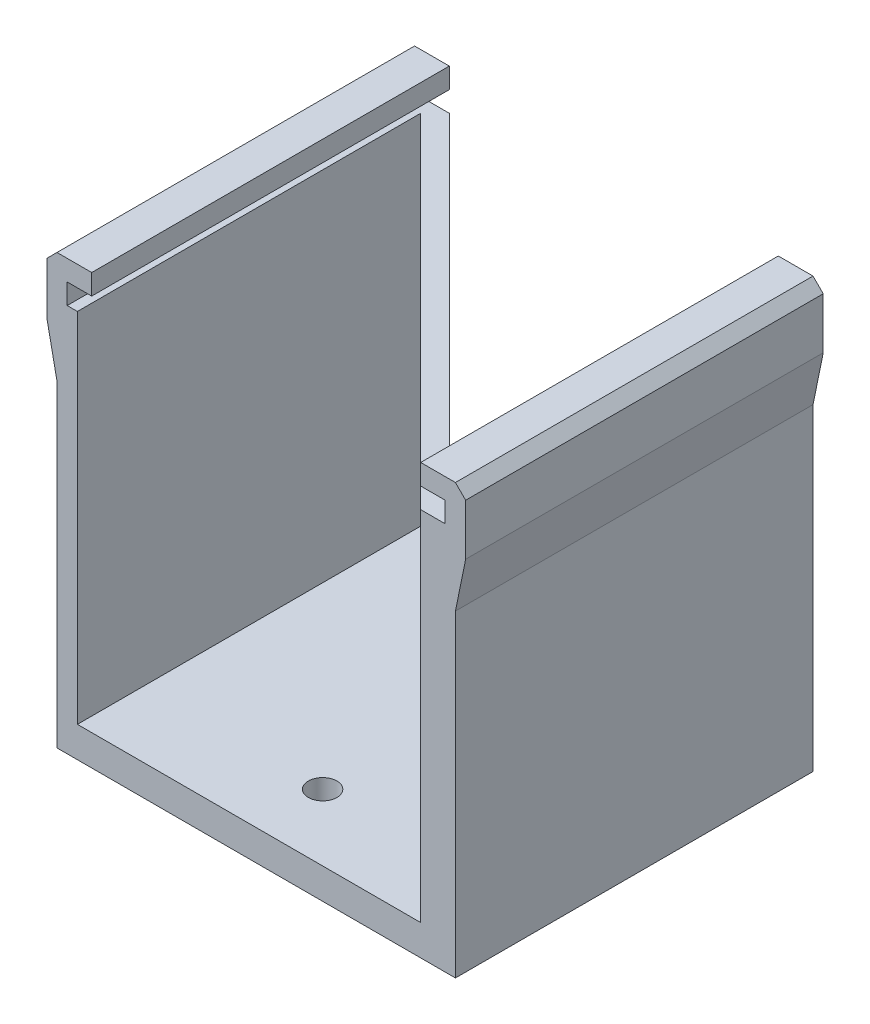
from build123d import *

# Parameters (mm, degrees)
SKETCH1_W            = 35
SKETCH1_H            = 35
BOSS_EXTRUDE1_DEPTH  = 3
BOSS_EXTRUDE2_DEPTH  = 35
SKETCH6_W            = 35
SKETCH6_H            = 38
BOSS_EXTRUDE8_DEPTH  = 2
SKETCH7_W            = 35
SKETCH7_H            = 38
BOSS_EXTRUDE9_DEPTH  = 2
SKETCH8_R            = 1.4
CUT_EXTRUDE1_DEPTH   = 10
SKETCH9_W            = 1
SKETCH9_H            = 35
BOSS_EXTRUDE10_DEPTH = 2
SKETCH10_W           = 3.4
SKETCH10_H           = 2
BOSS_EXTRUDE11_DEPTH = 35
BOSS_EXTRUDE12_DEPTH = 35


with BuildPart() as part:
    # Sketch1 → Boss-Extrude1 (new body)
    with BuildSketch(Plane(origin=(0, 0, 0), x_dir=(1, 0, 0), z_dir=(0, 1, 0))):
        with Locations((-17.5, 17.5)):
            Rectangle(SKETCH1_W, SKETCH1_H)
    extrude(amount=BOSS_EXTRUDE1_DEPTH)

    # Sketch2 → Boss-Extrude2 (add)
    with BuildSketch(Plane(origin=(0, 3, 0), x_dir=(1, 0, 0), z_dir=(0, 1, 0))):
        Polygon((-35, 33.6), (-1.4, 0), (0, 0), (0, 1.428427125), (-33.571572875, 35), (-35, 35), align=None)
    extrude(amount=BOSS_EXTRUDE2_DEPTH)

    # Sketch6 → Boss-Extrude8 (add)
    with BuildSketch(Plane(origin=(0, 0, 0), x_dir=(0, 0, -1), z_dir=(1, 0, 0))):
        with Locations((17.5, 19)):
            Rectangle(SKETCH6_W, SKETCH6_H)
    extrude(amount=BOSS_EXTRUDE8_DEPTH)

    # Sketch7 → Boss-Extrude9 (add)
    with BuildSketch(Plane.ZY.offset(35)):
        with Locations((-17.5, 19)):
            Rectangle(SKETCH7_W, SKETCH7_H)
    extrude(amount=BOSS_EXTRUDE9_DEPTH)

    # Sketch8 → Cut-Extrude1 (cut)
    with BuildSketch(Plane.XZ):
        with Locations((-17.5, -6.5)):
            Circle(SKETCH8_R)
        with Locations((-17.5, -28.5)):
            Circle(SKETCH8_R)
    extrude(amount=-CUT_EXTRUDE1_DEPTH, mode=Mode.SUBTRACT)

    # Sketch9 → Boss-Extrude10 (add)
    with BuildSketch(Plane(origin=(0, 38, 0), x_dir=(1, 0, 0), z_dir=(0, 1, 0))):
        with Locations((-36.5, 17.5)):
            Rectangle(SKETCH9_W, SKETCH9_H)
        with Locations((1.5, 17.5)):
            Rectangle(SKETCH9_W, SKETCH9_H)
    extrude(amount=BOSS_EXTRUDE10_DEPTH)

    # Sketch10 → Boss-Extrude11 (add)
    with BuildSketch(Plane.XY):
        with Locations((-35.3, 41)):
            Rectangle(SKETCH10_W, SKETCH10_H)
        with Locations((0.3, 41)):
            Rectangle(SKETCH10_W, SKETCH10_H)
    extrude(amount=-BOSS_EXTRUDE11_DEPTH)

    # Sketch11 → Boss-Extrude12 (add)
    with BuildSketch(Plane.XY):
        Polygon((-37, 42), (-38, 41), (-38, 36), (-37, 31.101020514), align=None)
        Polygon((2, 42), (3, 41), (3, 36), (2, 31.101020514), align=None)
    extrude(amount=-BOSS_EXTRUDE12_DEPTH)


solid = part.part
